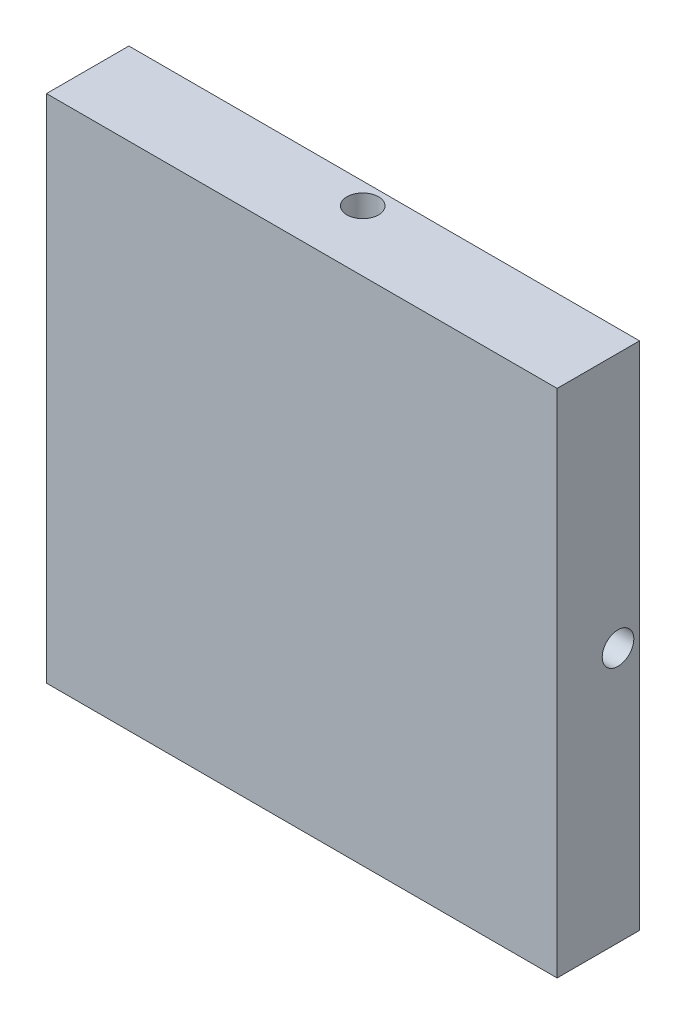
from build123d import *

# Parameters (mm, degrees)
SKETCH1_W           = 113.157
SKETCH1_H           = 113.157
SKETCH1_R           = 3.048
BOSS_EXTRUDE1_DEPTH = 8.73125
SKETCH1_3_W         = 113.157
SKETCH1_3_H         = 113.157
SKETCH1_3_R         = 3.33375
SKETCH1_3_R_2       = 50.8
SKETCH1_3_R_3       = 3.01625
SKETCH1_3_R_4       = 3.048
BOSS_EXTRUDE2_DEPTH = 9.525
SKETCH1_4_R         = 3.01625
BOSS_EXTRUDE3_DEPTH = 18.3515
CUT_EXTRUDE1_START  = -5.899214
SKETCH2_R           = 3.5
CUT_EXTRUDE1_DEPTH  = 5.899214
CIRPATTERN1_COUNT   = 4
SKETCH5_R           = 3.047999999
BOSS_EXTRUDE4_DEPTH = 9.525


with BuildPart() as part:
    # Sketch1 → Boss-Extrude1 (new body)
    with BuildSketch(Plane.XY):
        Rectangle(SKETCH1_W, SKETCH1_H)
        with Locations((-14.204320599, -16.928050104)):
            Circle(SKETCH1_R, mode=Mode.SUBTRACT)
    extrude(amount=BOSS_EXTRUDE1_DEPTH)

    # Sketch1_3 → Boss-Extrude2 (add)
    with BuildSketch(Plane.XY):
        Rectangle(SKETCH1_3_W, SKETCH1_3_H)
        with Locations((-43.8785, -43.8785)):
            Circle(SKETCH1_3_R, mode=Mode.SUBTRACT)
        with Locations((43.8785, -43.8785)):
            Circle(SKETCH1_3_R, mode=Mode.SUBTRACT)
        with Locations((43.8785, 43.8785)):
            Circle(SKETCH1_3_R, mode=Mode.SUBTRACT)
        with Locations((-43.8785, 43.8785)):
            Circle(SKETCH1_3_R, mode=Mode.SUBTRACT)
        Circle(SKETCH1_3_R_2, mode=Mode.SUBTRACT)
        with Locations((24.490207929, 29.186293283)):
            Circle(SKETCH1_3_R_3)
        with Locations((13.030967461, -35.802288852)):
            Circle(SKETCH1_3_R_3)
        Circle(SKETCH1_3_R_3)
        with Locations((-37.52117539, 6.615995569)):
            Circle(SKETCH1_3_R_3)
        with Locations((-14.204320599, -16.928050104)):
            Circle(SKETCH1_3_R_4)
    extrude(amount=-BOSS_EXTRUDE2_DEPTH)

    # Sketch1_4 → Boss-Extrude3 (add)
    with BuildSketch(Plane.XY):
        Circle(SKETCH1_4_R)
    extrude(amount=-BOSS_EXTRUDE3_DEPTH)

    # Sketch2 → Cut-Extrude1 (cut)
    with BuildSketch(Plane(origin=(0, 56.5785, 0), x_dir=(1, 0, 0), z_dir=(0, 1, 0)).offset(CUT_EXTRUDE1_START)):
        with Locations((0, 4.7625)):
            Circle(SKETCH2_R)
    cut_extrude1 = extrude(amount=CUT_EXTRUDE1_DEPTH, mode=Mode.SUBTRACT)

    # CirPattern1: Cut-Extrude1 ×4 about axis
    cirpattern1_axis = Axis((0, 0, -9.525), (0, 0, 1))
    for i in range(1, CIRPATTERN1_COUNT):
        add(cut_extrude1.rotate(cirpattern1_axis, i * 360 / CIRPATTERN1_COUNT), mode=Mode.SUBTRACT)

    # Sketch5 → Boss-Extrude4 (add)
    with BuildSketch(Plane.XY.offset(8.73125)):
        with Locations((-14.204320599, -16.928050104)):
            Circle(SKETCH5_R)
    extrude(amount=-BOSS_EXTRUDE4_DEPTH)


solid = part.part
